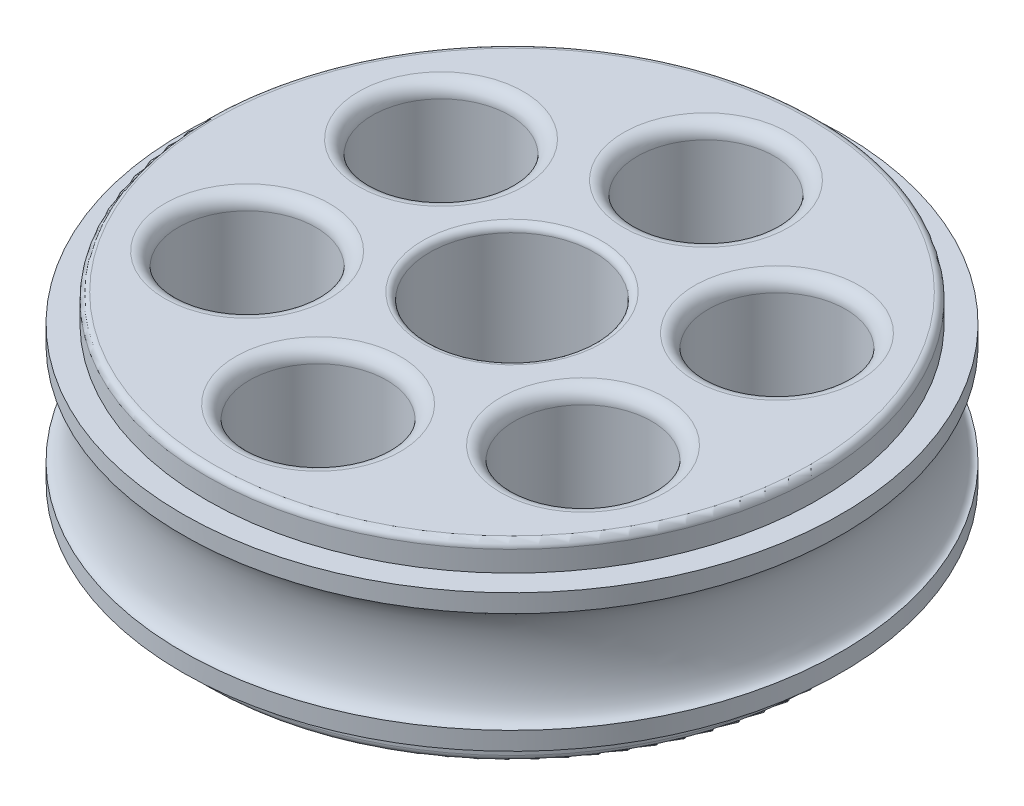
from build123d import *

# Parameters (mm, degrees)
SKETCH1_R          = 28.2575
STEP_DEPTH         = 2.54
SKETCH2_R          = 30.48
BODY_DEPTH         = 12.7
SKETCH3_R          = 28.2575
MIRROR_STEP_DEPTH  = 2.54
SKETCH4_R          = 7.62
CUT_EXTRUDE1_DEPTH = 18.78
FILLET1_R          = 0.635
SKETCH5_R          = 6.35
CUT_EXTRUDE2_DEPTH = 18.78
FILLET2_R          = 1.27
SKETCH6_RX         = 4.672159503
SKETCH6_RY         = 1.61863816


with BuildPart() as part:
    # Sketch1 → Step (new body)
    with BuildSketch(Plane(origin=(0, 0, 0), x_dir=(1, 0, 0), z_dir=(0, 1, 0))):
        Circle(SKETCH1_R)
    extrude(amount=STEP_DEPTH)

    # Sketch2 → Body (add)
    with BuildSketch(Plane(origin=(0, 2.54, 0), x_dir=(1, 0, 0), z_dir=(0, 1, 0))):
        Circle(SKETCH2_R)
    extrude(amount=BODY_DEPTH)

    # Sketch3 → Mirror_Step (add)
    with BuildSketch(Plane(origin=(0, 15.24, 0), x_dir=(1, 0, 0), z_dir=(0, 1, 0))):
        Circle(SKETCH3_R)
    extrude(amount=MIRROR_STEP_DEPTH)

    # Sketch4 → Cut-Extrude1 (cut, through all)
    with BuildSketch(Plane(origin=(0, 17.78, 0), x_dir=(1, 0, 0), z_dir=(0, 1, 0))):
        Circle(SKETCH4_R)
    extrude(amount=-CUT_EXTRUDE1_DEPTH, mode=Mode.SUBTRACT)

    # Fillet1
    fillet1_edges = [part.edges().sort_by_distance(p)[0] for p in [
        (-28.2575, 17.78, 0),
        (-7.62, 0, 0),
        (-7.62, 17.78, 0),
        (-28.2575, 0, 0),
    ]]
    fillet(fillet1_edges, radius=FILLET1_R)

    # Sketch5 → Cut-Extrude2 (cut, through all)
    with BuildSketch(Plane.XZ):
        with Locations((0, 17.93875)):
            Circle(SKETCH5_R)
        with Locations((15.535413212, 8.969375)):
            Circle(SKETCH5_R)
        with Locations((15.535413212, -8.969375)):
            Circle(SKETCH5_R)
        with Locations((0, -17.93875)):
            Circle(SKETCH5_R)
        with Locations((-15.535413212, -8.969375)):
            Circle(SKETCH5_R)
        with Locations((-15.535413212, 8.969375)):
            Circle(SKETCH5_R)
    extrude(amount=-CUT_EXTRUDE2_DEPTH, mode=Mode.SUBTRACT)

    # Fillet2
    fillet2_edges = [part.edges().sort_by_distance(p)[0] for p in [
        (9.185413212, 17.78, 8.969375),
        (9.185413212, 0, 8.969375),
        (9.185413212, 17.78, -8.969375),
        (9.185413212, 0, -8.969375),
        (-6.35, 17.78, -17.93875),
        (-6.35, 0, -17.93875),
        (-21.885413212, 17.78, -8.969375),
        (-21.885413212, 0, -8.969375),
        (-21.885413212, 17.78, 8.969375),
        (-21.885413212, 0, 8.969375),
        (-6.35, 17.78, 17.93875),
        (-6.35, 0, 17.93875),
    ]]
    fillet(fillet2_edges, radius=FILLET2_R)

    # Sketch6 → Groove (revolve, cut)
    with BuildSketch(Plane(origin=(0, 0, 0), x_dir=(0, 0, -1), z_dir=(1, 0, 0))):
        with Locations(Location((-30.48, 8.89), (0, 0, 90))):
            Ellipse(SKETCH6_RX, SKETCH6_RY)
    revolve(axis=Axis((0, 2.54, 0), (0, 1, 0)), mode=Mode.SUBTRACT)


solid = part.part
